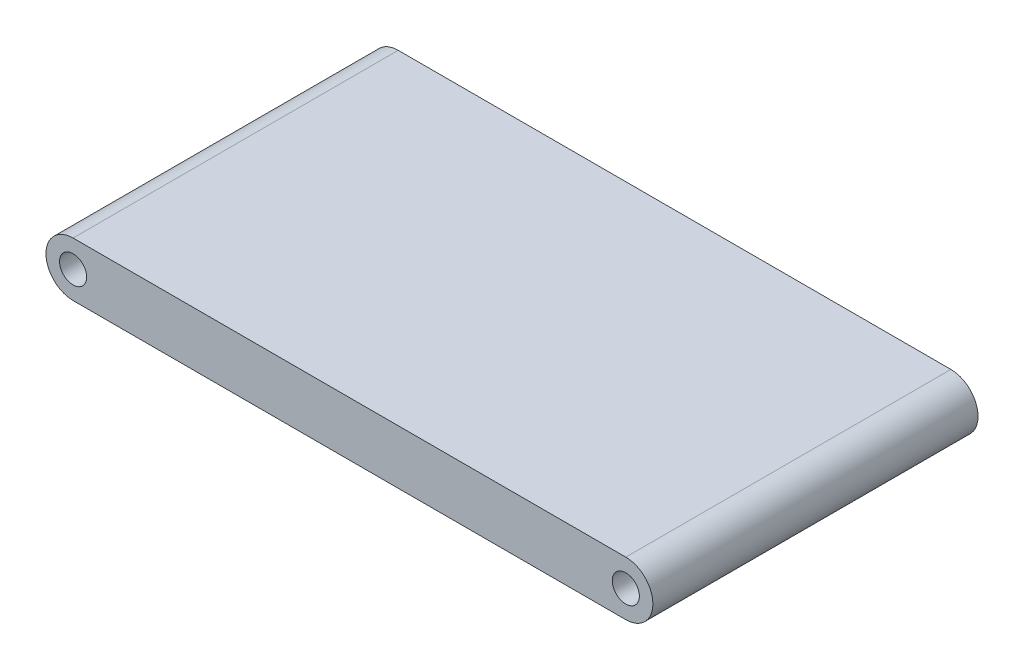
from build123d import *

# Parameters (mm, degrees)
SKETCH1_R           = 3.175
BOSS_EXTRUDE1_DEPTH = 76.2


with BuildPart() as part:
    # Sketch1 → Boss-Extrude1 (new body)
    with BuildSketch(Plane.XY):
        with BuildLine():
            Line((0, 6.35), (129.54, 6.35))
            ThreePointArc((129.54, 6.35), (135.89, 0), (129.54, -6.35))
            Line((129.54, -6.35), (0, -6.35))
            ThreePointArc((0, -6.35), (-6.35, 0), (0, 6.35))
        make_face()
        Circle(SKETCH1_R, mode=Mode.SUBTRACT)
        with Locations((129.54, 0)):
            Circle(SKETCH1_R, mode=Mode.SUBTRACT)
    extrude(amount=BOSS_EXTRUDE1_DEPTH)


solid = part.part
